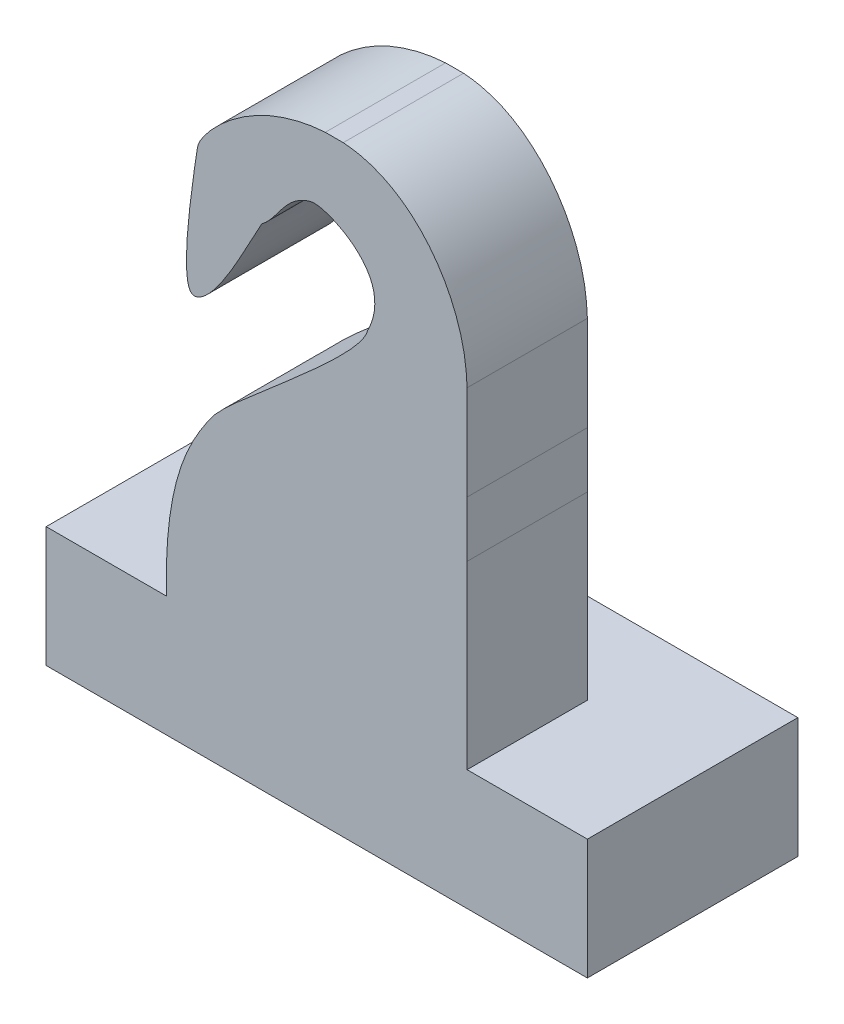
from build123d import *

# Parameters (mm, degrees)
SKETCH1_W                = 5
SKETCH1_H                = 5
BOSS_EXTRUDE1_DEPTH      = 2
SKETCH2_W                = 5
SKETCH2_H                = 2
BOSS_EXTRUDE2_DEPTH      = 8
SKETCH3_OUTSIDE_W        = 9.45
SKETCH3_OUTSIDE_H        = 14.45
CUT_EXTRUDE2_DEPTH       = 2.5
CUT_EXTRUDE2_DEPTH_BACK  = 4.5
SKETCH4_W                = 3.5
SKETCH4_H                = 2
BOSS_EXTRUDE3_DEPTH      = 2
BOSS_EXTRUDE3_DEPTH_BACK = 7
SKETCH5_W                = 1.5
SKETCH5_H                = 2
CUT_EXTRUDE3_DEPTH       = 8


with BuildPart() as part:
    # Sketch1 → Boss-Extrude1 (new body)
    with BuildSketch(Plane(origin=(0, 0, 0), x_dir=(1, 0, 0), z_dir=(0, 1, 0))):
        Rectangle(SKETCH1_W, SKETCH1_H)
    extrude(amount=BOSS_EXTRUDE1_DEPTH)

    # Sketch2 → Boss-Extrude2 (add)
    with BuildSketch(Plane(origin=(0, 2, 0), x_dir=(1, 0, 0), z_dir=(0, 1, 0))):
        Rectangle(SKETCH2_W, SKETCH2_H)
    extrude(amount=BOSS_EXTRUDE2_DEPTH)

    # Sketch3 outside → Cut-Extrude2 (cut, two sides)
    with BuildSketch(Plane.XY.offset(1)) as cut_extrude2_sk:
        with Locations((0, 5)):
            Rectangle(SKETCH3_OUTSIDE_W, SKETCH3_OUTSIDE_H)
        with BuildLine():
            Line((-2.5, 2), (-2.5, 0))
            Line((-2.5, 0), (2.5, 0))
            Line((2.5, 0), (2.5, 5))
            add(Edge.make_bspline(
                [(-0.913797876, 8.154353357), (-1.140290702, 7.764014656), (-1.655275227, 6.650653781), (-2.325037112, 6.455286198), (-2.005184786, 8.587856331), (-1.950557279, 8.936862033), (-1.049722674, 9.922936438), (1.431279674, 10.104693489), (2.482165571, 8.628994664), (2.518593991, 6.608795973), (2.490077622, 5.781893624), (2.5, 5)],
                knots=[0, 0, 0, 0, 0.166355066, 0.201541651, 0.335163153, 0.374433937, 0.554978708, 0.601657114, 0.794539594, 0.836784913, 1, 1, 1, 1], degree=3))
            add(Edge.make_bspline(
                [(0.846399905, 7.5), (1.269487929, 8.332056459), (0.146387492, 8.943361743), (-0.531494104, 8.784988095), (-0.648759024, 8.347108886), (-0.913797876, 8.154353357)],
                knots=[0, 0, 0, 0, 0.263206517, 0.363206517, 1, 1, 1, 1], degree=3))
            add(Edge.make_bspline(
                [(-2.5, 2), (-2.539795839, 3.63685244), (-2.078163398, 4.489565773), (-1.464924659, 5.353900226), (0.733429791, 7.043753996), (0.846399905, 7.5)],
                knots=[0, 0, 0, 0, 0.510185801, 0.610185801, 1, 1, 1, 1], degree=3))
        make_face(mode=Mode.SUBTRACT)
    extrude(amount=CUT_EXTRUDE2_DEPTH, mode=Mode.SUBTRACT)
    extrude(cut_extrude2_sk.sketch, amount=-CUT_EXTRUDE2_DEPTH_BACK, mode=Mode.SUBTRACT)

    # Sketch4 → Boss-Extrude3 (add, two sides)
    with BuildSketch(Plane(origin=(2.5, 0, 0), x_dir=(0, 0, -1), z_dir=(1, 0, 0))) as boss_extrude3_sk:
        with Locations((0.75, 1)):
            Rectangle(SKETCH4_W, SKETCH4_H)
    extrude(amount=BOSS_EXTRUDE3_DEPTH)
    extrude(boss_extrude3_sk.sketch, amount=-BOSS_EXTRUDE3_DEPTH_BACK)

    # Sketch5 → Cut-Extrude3 (cut, through all)
    with BuildSketch(Plane(origin=(2.5, 0, 0), x_dir=(0, 0, -1), z_dir=(1, 0, 0))):
        with Locations((-1.75, 1)):
            Rectangle(SKETCH5_W, SKETCH5_H)
    extrude(amount=-CUT_EXTRUDE3_DEPTH, mode=Mode.SUBTRACT)


solid = part.part
